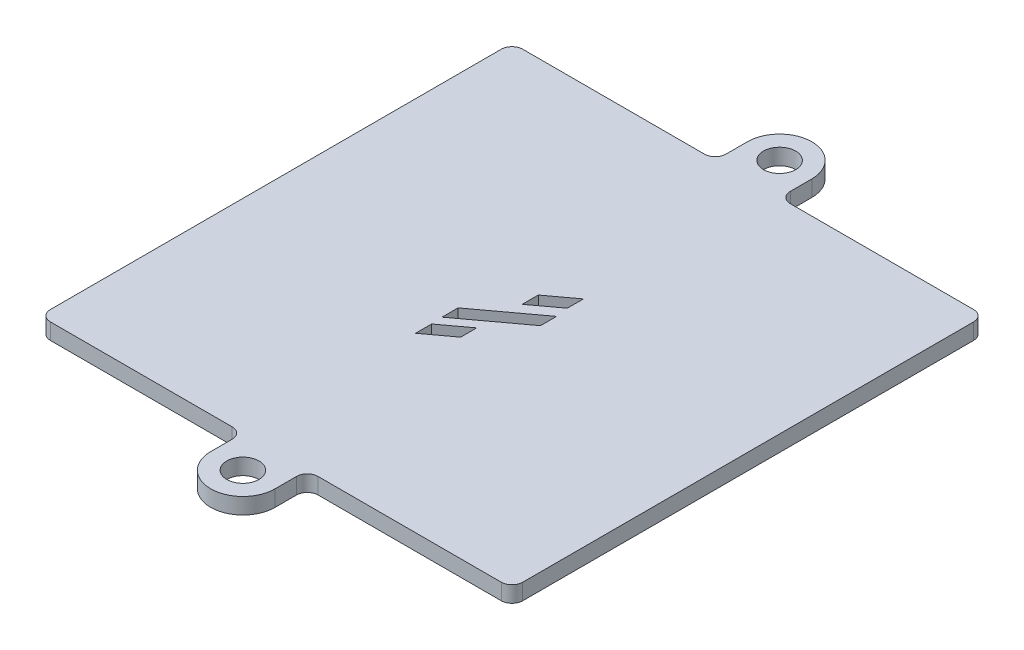
from build123d import *

# Parameters (mm, degrees)
SKETCH_1_R      = 1.5
EXTRUDE_1_DEPTH = 1.5


with BuildPart() as part:
    # 草图1 → 凸台-拉伸1 (new body)
    with BuildSketch(Plane(origin=(0, 0, 0), x_dir=(1, 0, 0), z_dir=(0, 1, 0))):
        with BuildLine():
            Line((-1, 0), (-18.069602783, 0))
            ThreePointArc((-18.069602783, 0), (-18.776709565, -0.292893219), (-19.069602783, -1))
            Line((-19.069602783, -1), (-19.069602783, -3))
            ThreePointArc((-19.069602783, -3), (-22.069602783, -6), (-25.069602783, -3))
            Line((-25.069602783, -3), (-25.069602783, -1))
            ThreePointArc((-25.069602783, -1), (-25.362496002, -0.292893219), (-26.069602783, 0))
            Line((-26.069602783, 0), (-43, 0))
            ThreePointArc((-43, 0), (-43.707106781, 0.292893219), (-44, 1))
            Line((-44, 1), (-44, 43))
            ThreePointArc((-44, 43), (-43.707106781, 43.707106781), (-43, 44))
            Line((-43, 44), (-26.069602783, 44))
            ThreePointArc((-26.069602783, 44), (-25.362496002, 44.292893219), (-25.069602783, 45))
            Line((-25.069602783, 45), (-25.069602783, 47))
            ThreePointArc((-25.069602783, 47), (-22.069602783, 50), (-19.069602783, 47))
            Line((-19.069602783, 47), (-19.069602783, 45))
            ThreePointArc((-19.069602783, 45), (-18.776709565, 44.292893219), (-18.069602783, 44))
            Line((-18.069602783, 44), (-1, 44))
            ThreePointArc((-1, 44), (-0.292893219, 43.707106781), (0, 43))
            Line((0, 43), (0, 1))
            ThreePointArc((0, 1), (-0.292893219, 0.292893219), (-1, 0))
        make_face()
        with Locations((-22.069602783, -3)):
            Circle(SKETCH_1_R, mode=Mode.SUBTRACT)
        with Locations((-22.069602783, 47)):
            Circle(SKETCH_1_R, mode=Mode.SUBTRACT)
        Polygon((-19.869912149, 24.021868684), (-19.869912149, 22.52053711), (-25.144061861, 18.620495369), (-25.144061861, 20.121826943), align=None, mode=Mode.SUBTRACT)
        Polygon((-20.026597006, 26.682534422), (-20.026597006, 25.181202847), (-22.444035318, 23.393595206), (-22.444035318, 24.894926781), align=None, mode=Mode.SUBTRACT)
        Polygon((-22.65940243, 19.377411479), (-22.65940243, 17.876079904), (-25.076840742, 16.088472263), (-25.076840742, 17.589803838), align=None, mode=Mode.SUBTRACT)
    extrude(amount=EXTRUDE_1_DEPTH)


solid = part.part
